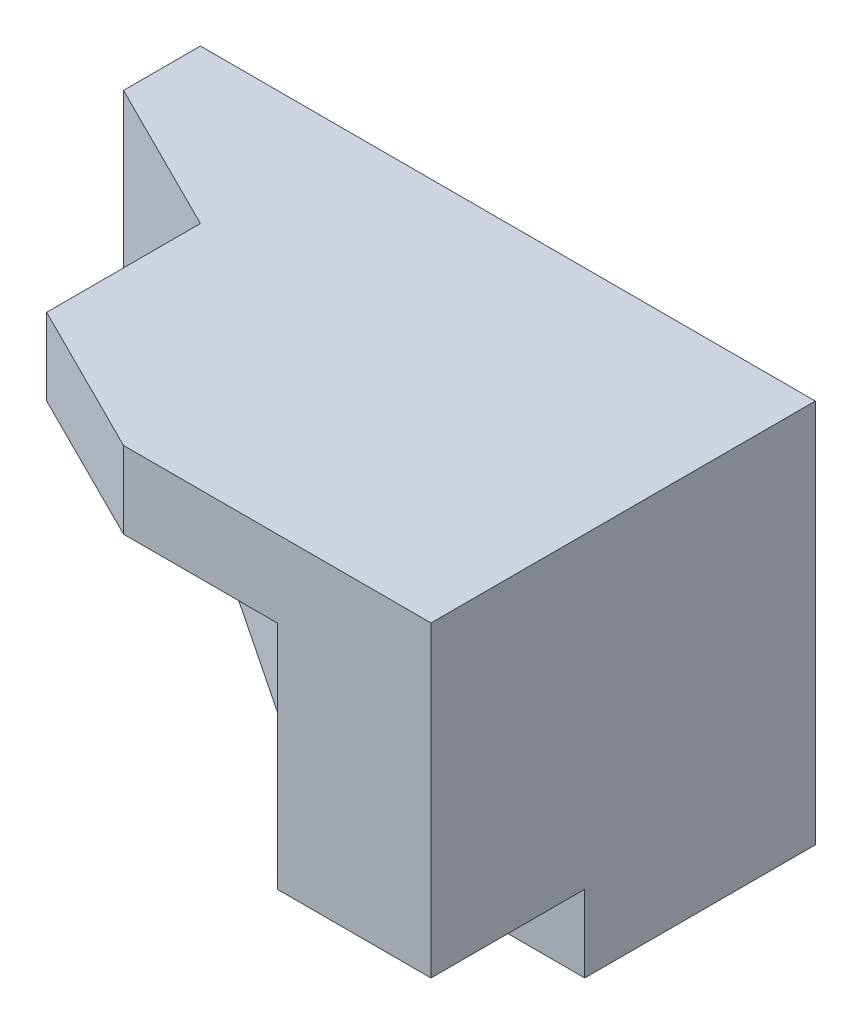
from build123d import *

# Parameters (mm, degrees)
SKETCH1_W            = 80
SKETCH1_H            = 50
BOSS_EXTRUDE1_DEPTH  = 10
SKETCH2_W            = 60
SKETCH2_H            = 10
CUT_EXTRUDE1_DEPTH   = 10
CUT_EXTRUDE2_DEPTH   = 10
BOSS_EXTRUDE2_DEPTH  = 10
BOSS_EXTRUDE4_DEPTH  = 40
SKETCH7_W            = 20
SKETCH7_H            = 10
BOSS_EXTRUDE5_DEPTH  = 40
SKETCH8_W            = 40
SKETCH8_H            = 10
BOSS_EXTRUDE6_DEPTH  = 40
BOSS_EXTRUDE7_DEPTH  = 10
BOSS_EXTRUDE8_DEPTH  = 30
BOSS_EXTRUDE9_DEPTH  = 30
BOSS_EXTRUDE11_DEPTH = 20
SKETCH14_W           = 80
SKETCH14_H           = 57.926255319
CUT_EXTRUDE3_DEPTH   = 20
BOSS_EXTRUDE12_DEPTH = 10


with BuildPart() as part:
    # Sketch1 → Boss-Extrude1 (new body)
    with BuildSketch(Plane.XY):
        with Locations((40, 25)):
            Rectangle(SKETCH1_W, SKETCH1_H)
    extrude(amount=BOSS_EXTRUDE1_DEPTH)

    # Sketch2 → Cut-Extrude1 (cut)
    with BuildSketch(Plane.XY.offset(10)):
        with Locations((30, 5)):
            Rectangle(SKETCH2_W, SKETCH2_H)
    extrude(amount=-CUT_EXTRUDE1_DEPTH, mode=Mode.SUBTRACT)

    # Sketch3 → Cut-Extrude2 (cut)
    with BuildSketch(Plane.XY.offset(10)):
        Polygon((40, 10), (0, 30), (0, 10), align=None)
    extrude(amount=-CUT_EXTRUDE2_DEPTH, mode=Mode.SUBTRACT)

    # Sketch4 → Boss-Extrude2 (add)
    with BuildSketch(Plane.XZ):
        Polygon((80, 0), (80, 30), (70, 30), (70, 20), (60, 10), (60, 0), align=None)
    extrude(amount=-BOSS_EXTRUDE2_DEPTH)

    # Sketch6 → Boss-Extrude4 (add)
    with BuildSketch(Plane.XZ.offset(-10)):
        Polygon((40, 10), (80, 10), (80, 40), (60, 40), (40, 30), align=None)
    extrude(amount=-BOSS_EXTRUDE4_DEPTH)

    # Sketch7 → Boss-Extrude5 (add)
    with BuildSketch(Plane.XZ.offset(-10)):
        with Locations((70, 45)):
            Rectangle(SKETCH7_W, SKETCH7_H)
    extrude(amount=-BOSS_EXTRUDE5_DEPTH)

    # Sketch8 → Boss-Extrude6 (add)
    with BuildSketch(Plane.XY.offset(50)):
        with Locations((60, 45)):
            Rectangle(SKETCH8_W, SKETCH8_H)
    extrude(amount=-BOSS_EXTRUDE6_DEPTH)

    # Sketch9 → Boss-Extrude7 (add)
    with BuildSketch(Plane(origin=(0, 40, 0), x_dir=(-1, 0, 0), z_dir=(0, -1, 0))):
        Polygon((-40, -50), (-20, -40), (-20, -23.413516985), (-20, -3.413516985), (-40, -3.413516985), align=None)
    extrude(amount=-BOSS_EXTRUDE7_DEPTH)

    # Sketch10 → Boss-Extrude8 (add)
    with BuildSketch(Plane(origin=(-4, 0, 8), x_dir=(-0.894427191, 0, -0.447213595), z_dir=(0.447213595, 0, -0.894427191))):
        Polygon((-71.55417528, 40), (-71.55417528, 10), (-4.472135955, 30), (-4.472135955, 50), (-49.193495505, 40), align=None)
    extrude(amount=BOSS_EXTRUDE8_DEPTH)

    # Sketch11 → Boss-Extrude9 (add)
    with BuildSketch(Plane(origin=(-4, 0, 8), x_dir=(-0.894427191, 0, -0.447213595), z_dir=(0.447213595, 0, -0.894427191))):
        Polygon((-49.193495505, 10), (-49.193495505, 16.666666667), (-4.472135955, 30), align=None)
    extrude(amount=BOSS_EXTRUDE9_DEPTH)

    # Sketch13 → Boss-Extrude11 (add)
    with BuildSketch(Plane(origin=(12, 24, 0), x_dir=(-0.894427191, 0.447213595, 0), z_dir=(-0.447213595, -0.894427191, 0))):
        Polygon((-31.304951685, -10), (-31.304951685, -30), (13.416407865, -10), align=None)
    extrude(amount=-BOSS_EXTRUDE11_DEPTH)

    # Sketch14 → Cut-Extrude3 (cut)
    with BuildSketch(Plane(origin=(0, 0, 0), x_dir=(-1, 0, 0), z_dir=(0, 0, -1))):
        with Locations((-40, 21.036872341)):
            Rectangle(SKETCH14_W, SKETCH14_H)
    extrude(amount=CUT_EXTRUDE3_DEPTH, mode=Mode.SUBTRACT)

    # Sketch15 → Boss-Extrude12 (add)
    with BuildSketch(Plane(origin=(-4, 0, 8), x_dir=(-0.894427191, 0, -0.447213595), z_dir=(0.447213595, 0, -0.894427191))):
        Polygon((-4.472135955, 50), (-26.83281573, 40), (-26.83281573, 50), align=None)
    extrude(amount=BOSS_EXTRUDE12_DEPTH)


solid = part.part
